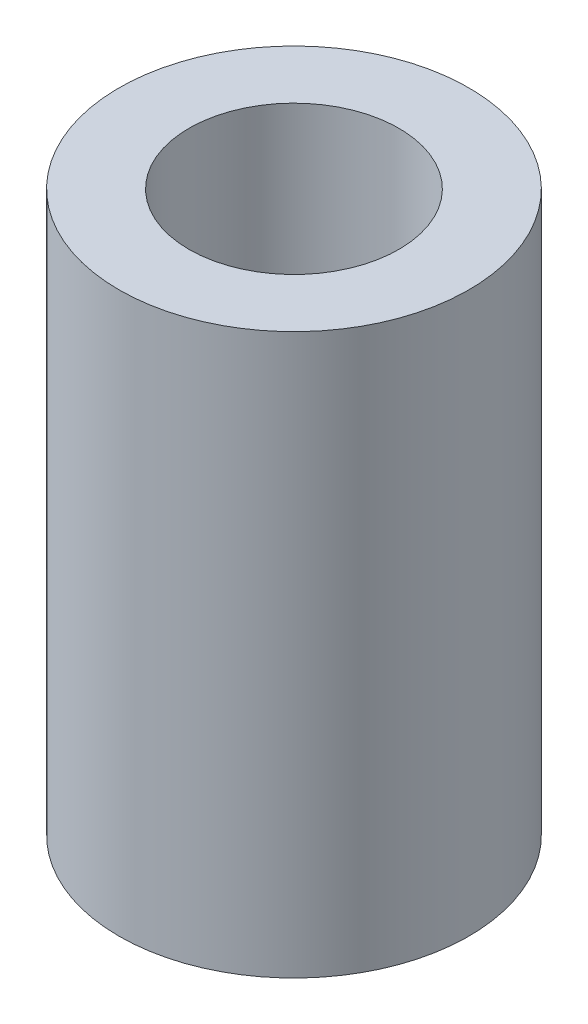
from build123d import *

# Parameters (mm, degrees)
SKETCH_1_R      = 2.5
SKETCH_1_R_2    = 1.5
EXTRUDE_1_DEPTH = 8


with BuildPart() as part:
    # 草图1 → 凸台-拉伸1 (new body)
    with BuildSketch(Plane(origin=(0, 0, 0), x_dir=(1, 0, 0), z_dir=(0, 1, 0))):
        Circle(SKETCH_1_R)
        Circle(SKETCH_1_R_2, mode=Mode.SUBTRACT)
    extrude(amount=EXTRUDE_1_DEPTH)


solid = part.part
